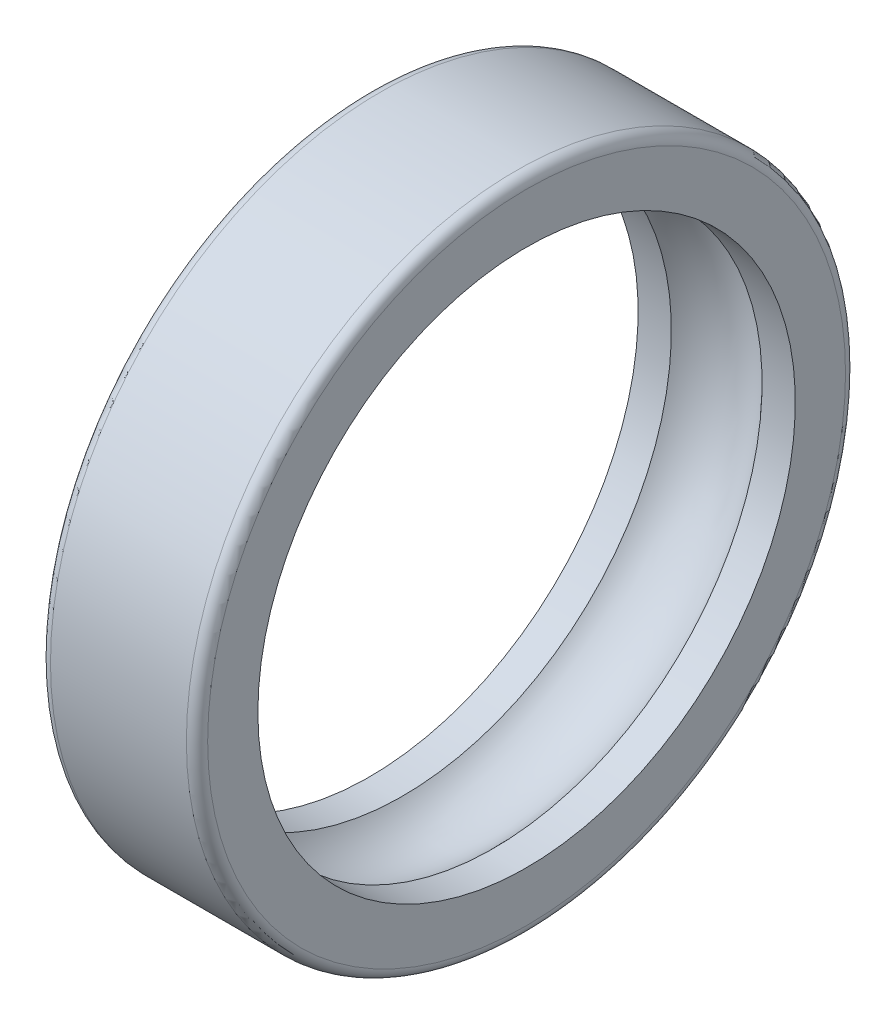
from build123d import *

# Parameters (mm, degrees)
FILLET1_R    = 2.1
SCALE1_SCALE = 1.2
SCALE2_SCALE = 0.1


with BuildPart() as part:
    # Sketch1 → Revolve1 (revolve)
    with BuildSketch(Plane.XY):
        with BuildLine():
            Line((-15.5, 65), (15.5, 65))
            Line((15.5, 65), (15.5, 53))
            Line((15.5, 53), (8.94427191, 53))
            ThreePointArc((8.94427191, 53), (0, 57), (-8.94427191, 53))
            Line((-8.94427191, 53), (-15.5, 53))
            Line((-15.5, 53), (-15.5, 65))
        make_face()
    revolve(axis=Axis((-12.809085422, 0, 0), (1, 0, 0)))

    # Fillet1
    fillet1_edges = [part.edges().sort_by_distance(p)[0] for p in [
        (15.5, -65, 0),
        (-15.5, -65, 0),
    ]]
    fillet(fillet1_edges, radius=FILLET1_R)


with BuildPart() as part_1:
    # Scale1: scaled about (0, 0, 0)
    add(part.part.scale(SCALE1_SCALE))


with BuildPart() as part_2:
    # Scale2: scaled about (0, 0, 0)
    add(part_1.part.scale(SCALE2_SCALE))


solid = part_2.part
